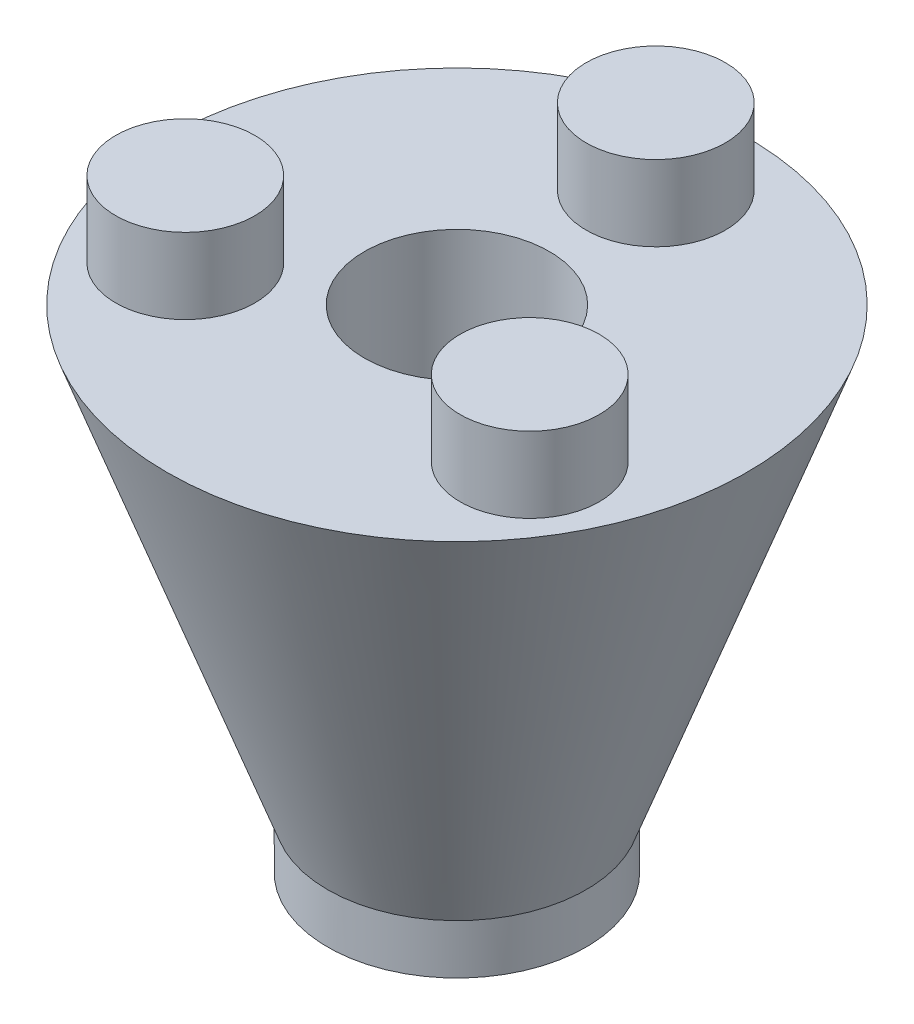
from build123d import *

# Parameters (mm, degrees)
SKETCH1_R            = 6.500000081
ANGLEBODY_DEPTH      = 22.225
ANGLEBODY_DRAFT      = -20
SKETCH2_R            = 4.649999971
SKETCH2_R_2          = 1.93499994
CENTERHOLE_DEPTH     = 31.325606131
F_40TPEGS_DEPTH      = 3.80000002
SKETCH3_R            = 6.500000081
SKETCH3_R_2          = 3.300000004
F_20TINTERFACE_DEPTH = 2.50000008


with BuildPart() as part:
    # Sketch1 → AngleBody (with draft: the straight prism first)
    with BuildSketch(Plane(origin=(0, 0, 0), x_dir=(1, 0, 0), z_dir=(0, 1, 0))):
        Circle(SKETCH1_R)
    extrude(amount=ANGLEBODY_DEPTH)
    # AngleBody: the draft: its side faces are tilted about the plane it starts from
    anglebody_sides = [part.faces().sort_by_distance(p)[0] for p in [
        (-6.500000081, 11.1125, 0),
    ]]
    draft(anglebody_sides, Plane(origin=(0, 0, 0), x_dir=(1, 0, 0), z_dir=(0, 1, 0)), ANGLEBODY_DRAFT)

    # Sketch2 → CenterHole (cut, through all)
    with BuildSketch(Plane(origin=(0, 22.225, 0), x_dir=(1, 0, 0), z_dir=(0, 1, 0))):
        with Locations(Location((0, 0, 0), (0, 0, 270))):
            Circle(SKETCH2_R)
        Circle(SKETCH2_R_2, mode=Mode.SUBTRACT)
        Circle(SKETCH2_R_2)
    extrude(amount=-CENTERHOLE_DEPTH, mode=Mode.SUBTRACT)

    # Sketch2_3 → 40tPegs (add)
    with BuildSketch(Plane(origin=(0, 22.225, 0), x_dir=(1, 0, 0), z_dir=(0, 1, 0))):
        with BuildLine():
            ThreePointArc((3.499999985, 10.000000066), (-1.749999993, 13.031088966), (-1.749999992, 6.968911166))
            Line((-1.749999992, 6.968911166), (0, 10.000000066))
            Line((0, 10.000000066), (1.749999992, 6.968911166))
            ThreePointArc((1.749999992, 6.968911166), (3.0310889, 8.250000073), (3.499999985, 10.000000066))
        make_face()
        with BuildLine():
            Line((0, 10.000000066), (-1.749999992, 6.968911166))
            ThreePointArc((-1.749999992, 6.968911166), (0, 6.500000081), (1.749999992, 6.968911166))
            Line((1.749999992, 6.968911166), (0, 10.000000066))
        make_face()
        with BuildLine():
            ThreePointArc((3.499999985, 10.000000066), (-1.749999993, 13.031088966), (-1.749999992, 6.968911166))
            Line((-1.749999992, 6.968911166), (0, 10.000000066))
            Line((0, 10.000000066), (1.749999992, 6.968911166))
            ThreePointArc((1.749999992, 6.968911166), (3.0310889, 8.250000073), (3.499999985, 10.000000066))
        make_face()
        with BuildLine():
            Line((0, 10.000000066), (-1.749999992, 6.968911166))
            ThreePointArc((-1.749999992, 6.968911166), (0, 6.500000081), (1.749999992, 6.968911166))
            Line((1.749999992, 6.968911166), (0, 10.000000066))
        make_face()
        with BuildLine():
            Line((-6.910254103, -1.968911133), (-8.660254095, -5.000000033))
            Line((-8.660254095, -5.000000033), (-5.16025411, -5.000000033))
            ThreePointArc((-5.16025411, -5.000000033), (-5.629165195, -3.25000004), (-6.910254103, -1.968911133))
        make_face()
        with BuildLine():
            Line((-5.16025411, -5.000000033), (-8.660254095, -5.000000033))
            Line((-8.660254095, -5.000000033), (-6.910254103, -1.968911133))
            ThreePointArc((-6.910254103, -1.968911133), (-11.691342995, -6.750000026), (-5.16025411, -5.000000033))
        make_face()
        with BuildLine():
            Line((-6.910254103, -1.968911133), (-8.660254095, -5.000000033))
            Line((-8.660254095, -5.000000033), (-5.16025411, -5.000000033))
            ThreePointArc((-5.16025411, -5.000000033), (-5.629165195, -3.25000004), (-6.910254103, -1.968911133))
        make_face()
        with BuildLine():
            Line((-5.16025411, -5.000000033), (-8.660254095, -5.000000033))
            Line((-8.660254095, -5.000000033), (-6.910254103, -1.968911133))
            ThreePointArc((-6.910254103, -1.968911133), (-11.691342995, -6.750000026), (-5.16025411, -5.000000033))
        make_face()
        with BuildLine():
            ThreePointArc((6.910254103, -1.968911133), (5.629165195, -3.25000004), (5.16025411, -5.000000033))
            Line((5.16025411, -5.000000033), (8.660254095, -5.000000033))
            Line((8.660254095, -5.000000033), (6.910254103, -1.968911133))
        make_face()
        with BuildLine():
            Line((8.660254095, -5.000000033), (5.16025411, -5.000000033))
            ThreePointArc((5.16025411, -5.000000033), (8.660254095, -8.500000018), (12.16025408, -5.000000033))
            ThreePointArc((12.16025408, -5.000000033), (10.410254088, -1.968911133), (6.910254103, -1.968911133))
            Line((6.910254103, -1.968911133), (8.660254095, -5.000000033))
        make_face()
        with BuildLine():
            ThreePointArc((6.910254103, -1.968911133), (5.629165195, -3.25000004), (5.16025411, -5.000000033))
            Line((5.16025411, -5.000000033), (8.660254095, -5.000000033))
            Line((8.660254095, -5.000000033), (6.910254103, -1.968911133))
        make_face()
        with BuildLine():
            Line((8.660254095, -5.000000033), (5.16025411, -5.000000033))
            ThreePointArc((5.16025411, -5.000000033), (8.660254095, -8.500000018), (12.16025408, -5.000000033))
            ThreePointArc((12.16025408, -5.000000033), (10.410254088, -1.968911133), (6.910254103, -1.968911133))
            Line((6.910254103, -1.968911133), (8.660254095, -5.000000033))
        make_face()
    extrude(amount=F_40TPEGS_DEPTH)

    # Sketch3 → 20tInterface (add)
    with BuildSketch(Plane.XZ):
        with Locations(Location((0, 0, 0), (0, 0, 270))):
            Circle(SKETCH3_R)
        with Locations(Location((0, 0, 0), (0, 0, 270))):
            Circle(SKETCH3_R_2, mode=Mode.SUBTRACT)
    extrude(amount=F_20TINTERFACE_DEPTH)


solid = part.part
